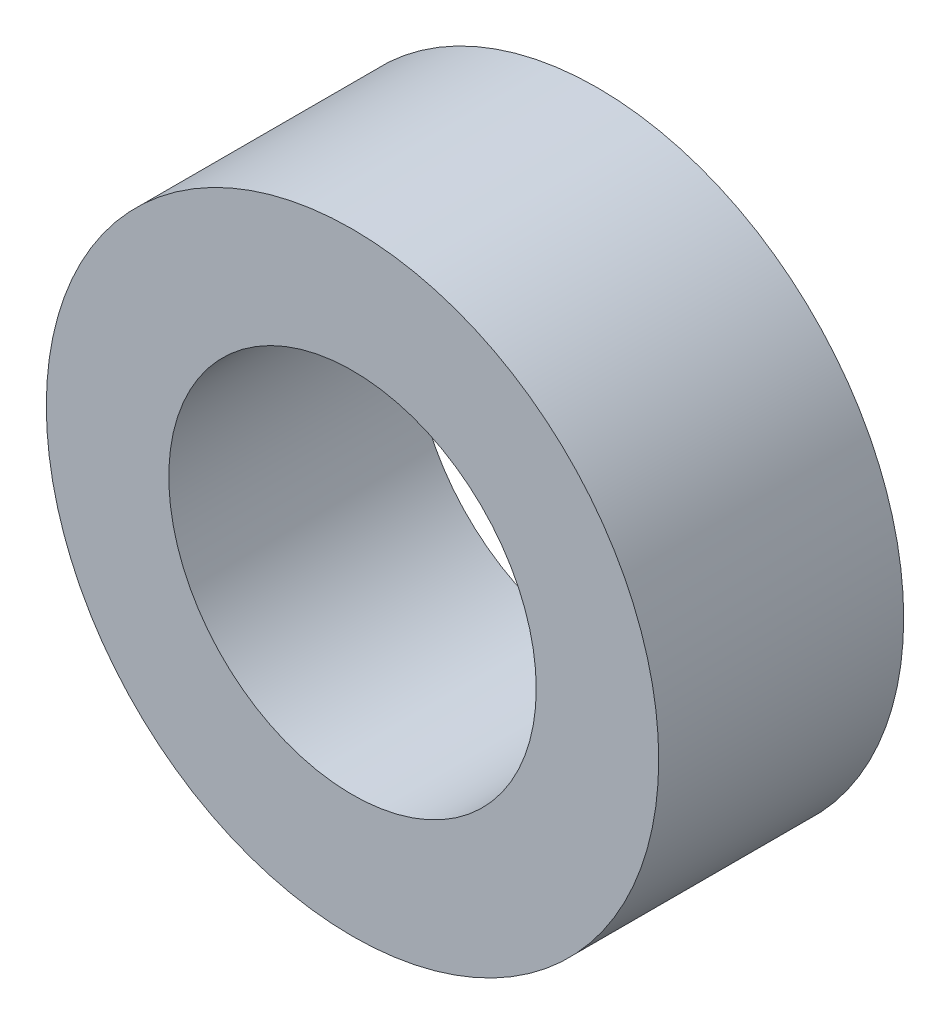
from build123d import *

# Parameters (mm, degrees)
SKETCH_1_R      = 2.5
SKETCH_1_R_2    = 1.5
EXTRUDE_1_DEPTH = 2


with BuildPart() as part:
    # Эскиз1 → Бобышка-Вытянуть1 (new body)
    with BuildSketch(Plane.XY):
        Circle(SKETCH_1_R)
        Circle(SKETCH_1_R_2, mode=Mode.SUBTRACT)
    extrude(amount=EXTRUDE_1_DEPTH)


solid = part.part
